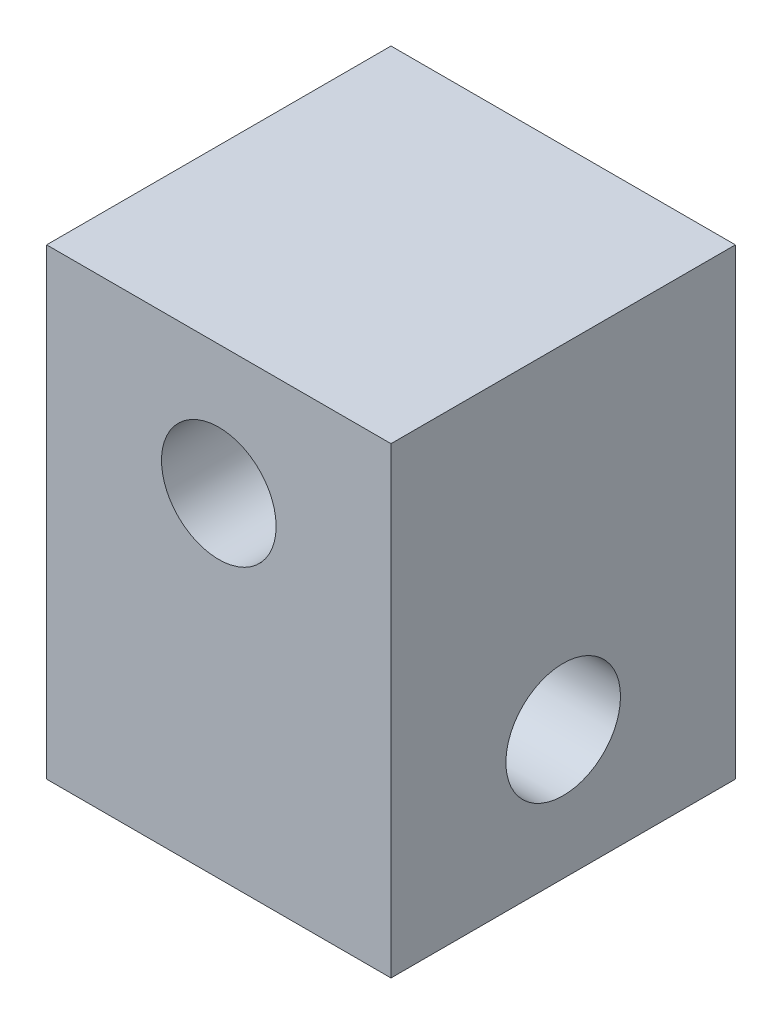
from build123d import *

# Parameters (mm, degrees)
SKETCH1_W                  = 10.922
SKETCH1_H                  = 8.128
BOSS_EXTRUDE1_DEPTH        = 8.128
M2_5_CLEARANCE_HOLE1_D     = 2.7051
M2_5_CLEARANCE_HOLE1_DEPTH = 8.128
M2_5_CLEARANCE_HOLE2_D     = 2.7051
M2_5_CLEARANCE_HOLE2_DEPTH = 8.128


with BuildPart() as part:
    # Sketch1 → Boss-Extrude1 (new body)
    with BuildSketch(Plane(origin=(-4.064, 0, 0), x_dir=(0, -1, 0), z_dir=(-1, 0, 0))):
        with Locations((-5.461, 0)):
            Rectangle(SKETCH1_W, SKETCH1_H)
    extrude(amount=-BOSS_EXTRUDE1_DEPTH)

    # M2.5 Clearance Hole1
    with Locations(Plane(origin=(4.064, 0, 0), x_dir=(0, 0, -1), z_dir=(1, 0, 0))):
        with Locations((0, 3.048)):
            Hole(M2_5_CLEARANCE_HOLE1_D / 2, depth=M2_5_CLEARANCE_HOLE1_DEPTH)

    # M2.5 Clearance Hole2
    with Locations(Plane.XY.offset(4.064)):
        with Locations((0, 7.874)):
            Hole(M2_5_CLEARANCE_HOLE2_D / 2, depth=M2_5_CLEARANCE_HOLE2_DEPTH)


solid = part.part
